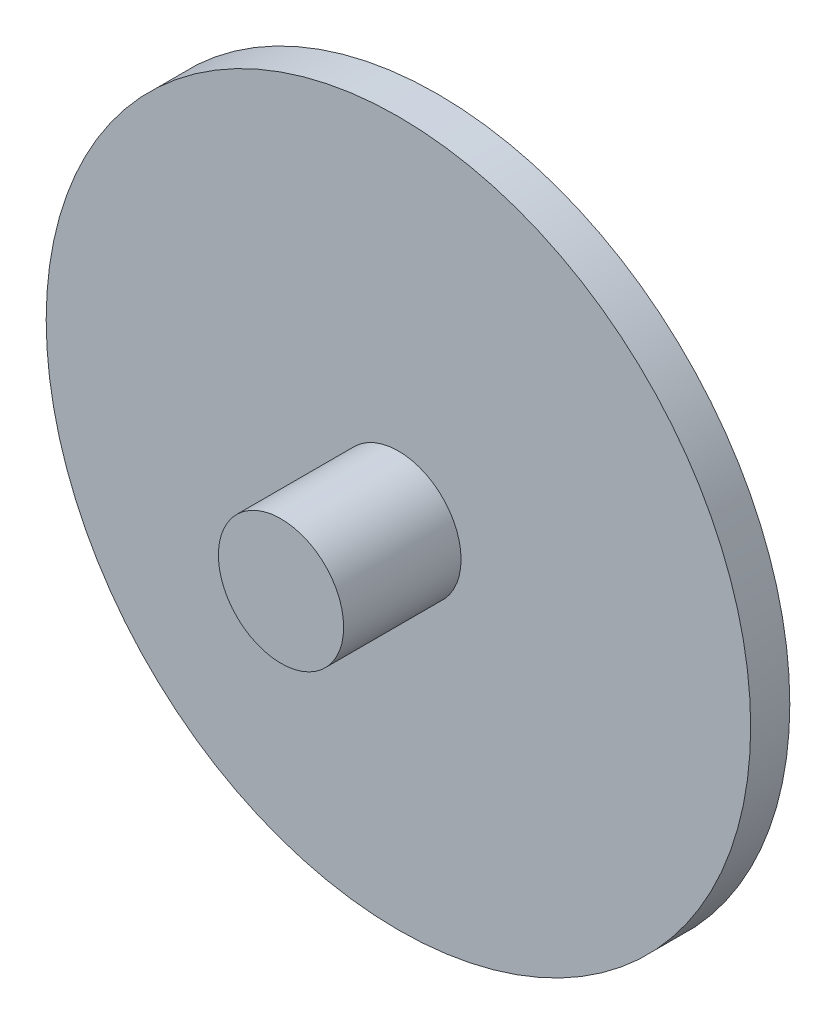
from build123d import *

# Parameters (mm, degrees)
SKETCH1_R                = 8
BOSS_EXTRUDE1_DEPTH      = 20
BOSS_EXTRUDE1_DEPTH_BACK = 15
SKETCH2_R                = 45
BOSS_EXTRUDE2_DEPTH      = 5
SKETCH3_R                = 2
CUT_EXTRUDE1_DEPTH       = 10
CUT_EXTRUDE1_DEPTH_BACK  = 15


with BuildPart() as part:
    # Sketch1 → Boss-Extrude1 (new body, two sides)
    with BuildSketch(Plane.XY) as boss_extrude1_sk:
        Circle(SKETCH1_R)
    extrude(amount=BOSS_EXTRUDE1_DEPTH)
    extrude(boss_extrude1_sk.sketch, amount=-BOSS_EXTRUDE1_DEPTH_BACK)

    # Sketch2 → Boss-Extrude2 (add)
    with BuildSketch(Plane.XY):
        Circle(SKETCH2_R)
    extrude(amount=BOSS_EXTRUDE2_DEPTH)

    # Sketch3 → Cut-Extrude1 (cut, two sides)
    with BuildSketch(Plane.XY) as cut_extrude1_sk:
        Circle(SKETCH3_R)
    extrude(amount=CUT_EXTRUDE1_DEPTH, mode=Mode.SUBTRACT)
    extrude(cut_extrude1_sk.sketch, amount=-CUT_EXTRUDE1_DEPTH_BACK, mode=Mode.SUBTRACT)


solid = part.part
